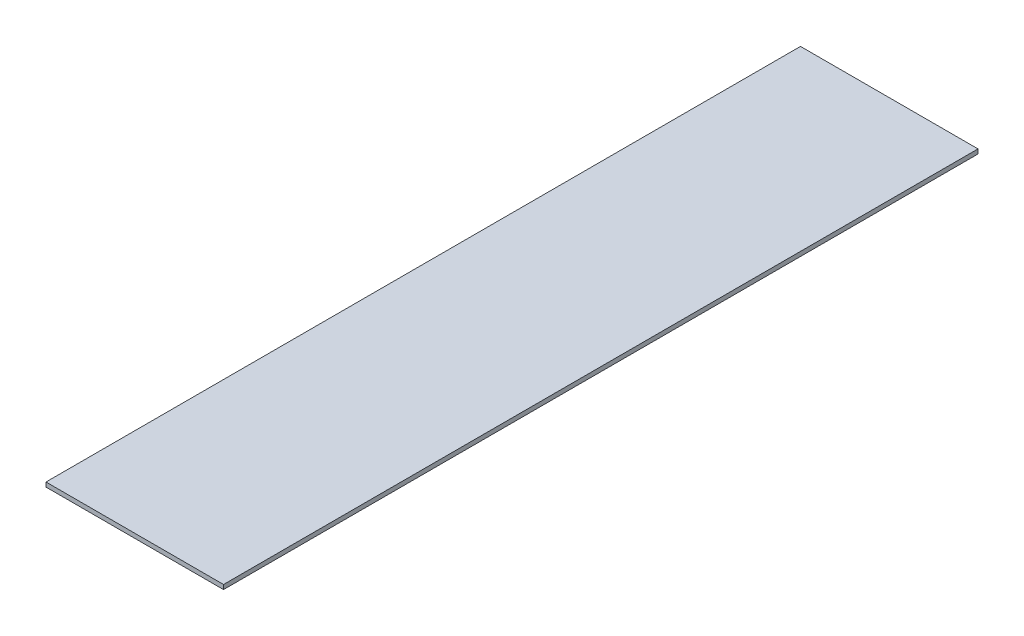
from build123d import *

# Parameters (mm, degrees)
ESQUISSE1_W      = 400
ESQUISSE1_H      = 1700
EXTRUSION1_DEPTH = 10


with BuildPart() as part:
    # Esquisse1 → Extrusion1 (new body)
    with BuildSketch(Plane(origin=(0, 0, 0), x_dir=(1, 0, 0), z_dir=(0, 1, 0))):
        with Locations((200, 850)):
            Rectangle(ESQUISSE1_W, ESQUISSE1_H)
    extrude(amount=EXTRUSION1_DEPTH)


solid = part.part
